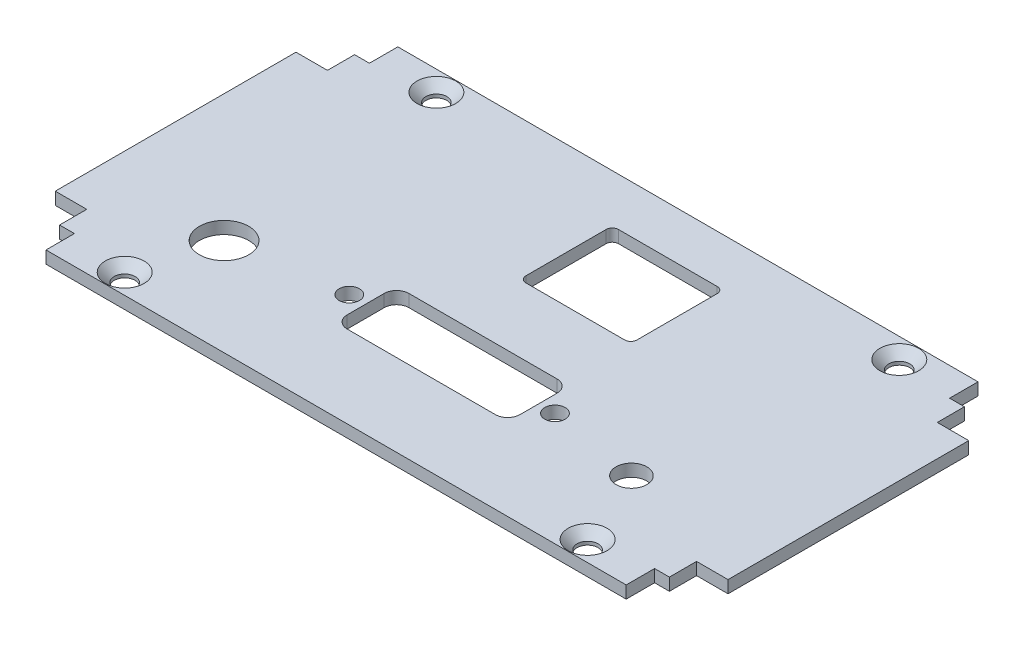
from build123d import *

# Parameters (mm, degrees)
SKETCH_1_W            = 109
SKETCH_1_H            = 57
EXTRUDE_1_DEPTH       = 2
CUT_EXTRUDE_1_DEPTH   = 3
MIRROR_2_COPY_1_DEPTH = 3
SKETCH_3_R            = 4
SKETCH_3_R_2          = 2.5
CUT_EXTRUDE_2_DEPTH   = 3
SKETCH_4_R            = 1.65
CUT_EXTRUDE_3_DEPTH   = 2
SKETCH_5_W            = 18
SKETCH_5_H            = 15
CUT_EXTRUDE_4_DEPTH   = 3
FILLET_1_R            = 1


with BuildPart() as part:
    # Эскиз1 → Бобышка-Вытянуть1 (new body)
    with BuildSketch(Plane(origin=(0, 0, 0), x_dir=(1, 0, 0), z_dir=(0, 1, 0))):
        Rectangle(SKETCH_1_W, SKETCH_1_H)
    extrude(amount=EXTRUDE_1_DEPTH)

    # Эскиз2 → Вырез-Вытянуть1 (cut, through all)
    with BuildSketch(Plane(origin=(0, 2, 0), x_dir=(1, 0, 0), z_dir=(0, 1, 0))):
        Polygon((49.4, 19.5), (54.5, 19.5), (54.5, 28.5), (47, 28.5), (47, 23.9), (49.4, 23.9), align=None)
    cut_extrude_1 = extrude(amount=-CUT_EXTRUDE_1_DEPTH, mode=Mode.SUBTRACT)

    # Зеркальное отражение1: Вырез-Вытянуть1 across plane
    add(cut_extrude_1.mirror(Plane(origin=(0, 0, 0), x_dir=(0, 0, 1), z_dir=(1, 0, 0))), mode=Mode.SUBTRACT)

    # Зеркальное отражение2: Вырез-Вытянуть1 across plane
    add(cut_extrude_1.mirror(Plane.XY), mode=Mode.SUBTRACT)

    # Зеркальное отражение2 copy 1 sketch → Зеркальное отражение2 copy 1 (cut, through all)
    with BuildSketch(Plane(origin=(0, 2, 0), x_dir=(-1, 0, 0), z_dir=(0, 1, 0))):
        Polygon((49.4, 19.5), (54.5, 19.5), (54.5, 28.5), (47, 28.5), (47, 23.9), (49.4, 23.9), align=None)
    extrude(amount=-MIRROR_2_COPY_1_DEPTH, mode=Mode.SUBTRACT)

    # Эскиз3 → Вырез-Вытянуть2 (cut, through all)
    with BuildSketch(Plane(origin=(0, 2, 0), x_dir=(1, 0, 0), z_dir=(0, 1, 0))):
        with Locations((-33.9, -12.75)):
            Circle(SKETCH_3_R)
        with Locations((32.1, -12.75)):
            Circle(SKETCH_3_R_2)
    extrude(amount=-CUT_EXTRUDE_2_DEPTH, mode=Mode.SUBTRACT)

    # Эскиз4 → Вырез-Вытянуть3 (cut)
    with BuildSketch(Plane(origin=(0, 2, 0), x_dir=(1, 0, 0), z_dir=(0, 1, 0))):
        with Locations((17.16, -10.2)):
            Circle(SKETCH_4_R)
        with Locations((-16.16, -10.2)):
            Circle(SKETCH_4_R)
        with BuildLine():
            Line((-11.5, -5.2), (12.5, -5.2))
            ThreePointArc((12.5, -5.2), (13.914213562, -5.785786438), (14.5, -7.2))
            Line((14.5, -7.2), (14.5, -13.2))
            ThreePointArc((14.5, -13.2), (13.914213562, -14.614213562), (12.5, -15.2))
            Line((12.5, -15.2), (-11.5, -15.2))
            ThreePointArc((-11.5, -15.2), (-12.914213562, -14.614213562), (-13.5, -13.2))
            Line((-13.5, -13.2), (-13.5, -7.2))
            ThreePointArc((-13.5, -7.2), (-12.914213562, -5.785786438), (-11.5, -5.2))
        make_face()
    extrude(amount=-CUT_EXTRUDE_3_DEPTH, mode=Mode.SUBTRACT)

    # Эскиз5 → Вырез-Вытянуть4 (cut, through all)
    with BuildSketch(Plane(origin=(0, 2, 0), x_dir=(1, 0, 0), z_dir=(0, 1, 0))):
        with Locations((4.5, 13.25)):
            Rectangle(SKETCH_5_W, SKETCH_5_H)
    extrude(amount=-CUT_EXTRUDE_4_DEPTH, mode=Mode.SUBTRACT)

    # Эскиз6 → Зенковка для винта с полупотайной головкой M31 (revolve, cut)
    with BuildSketch(Plane(origin=(37.5, 2, -25.25), x_dir=(0, 0, 1), z_dir=(1, 0, 0))):
        Polygon((0, 0), (0, 2.001), (1.7, 2.001), (1.7, 1.45), (3.15, 0), align=None)
    hole_wizard_m31 = revolve(axis=Axis((37.5, 8.35, -25.25), (0, -1, 0)), mode=Mode.SUBTRACT)

    # Зеркальное отражение3: Зенковка для винта с полупотайной головкой M31 across plane
    add(hole_wizard_m31.mirror(Plane.XY), mode=Mode.SUBTRACT)

    # Зеркальное отражение4: Зенковка для винта с полупотайной головкой M31 across plane
    add(hole_wizard_m31.mirror(Plane(origin=(0, 0, 0), x_dir=(0, 0, 1), z_dir=(1, 0, 0))), mode=Mode.SUBTRACT)

    # Зеркальное отражение4 copy 1 sketch → Зеркальное отражение4 copy 1 (revolve, cut)
    with BuildSketch(Plane(origin=(-37.5, 2, 25.25), x_dir=(0, 0, -1), z_dir=(-1, 0, 0))):
        Polygon((0, 0), (0, 2.001), (1.7, 2.001), (1.7, 1.45), (3.15, 0), align=None)
    revolve(axis=Axis((-37.5, 8.35, 25.25), (0, -1, 0)), mode=Mode.SUBTRACT)

    # Скругление1
    fillet_1_edges = [part.edges().sort_by_distance(p)[0] for p in [
        (13.5, 1, -20.75),
        (13.5, 1, -5.75),
        (-4.5, 1, -5.75),
        (-4.5, 1, -20.75),
    ]]
    fillet(fillet_1_edges, radius=FILLET_1_R)


solid = part.part
